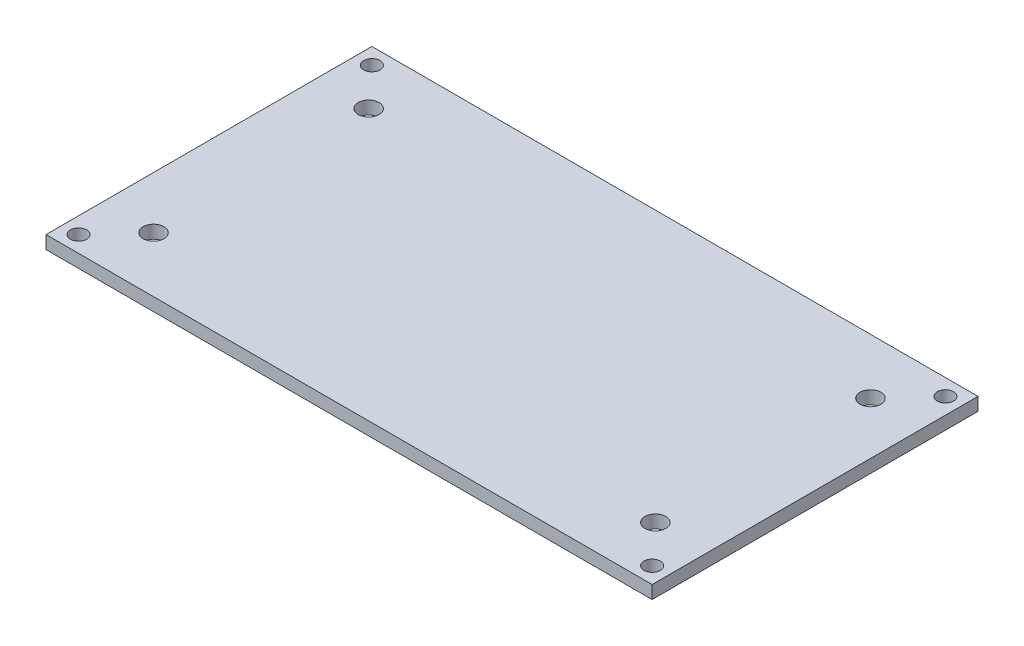
from build123d import *

# Parameters (mm, degrees)
SKETCH1_W           = 93
SKETCH1_H           = 50
BOSS_EXTRUDE1_DEPTH = 2
SKETCH2_R           = 1.25
CUT_EXTRUDE1_DEPTH  = 2
SKETCH3_R           = 1.6
CUT_EXTRUDE2_DEPTH  = 2


with BuildPart() as part:
    # Sketch1 → Boss-Extrude1 (new body)
    with BuildSketch(Plane(origin=(0, 0, 0), x_dir=(1, 0, 0), z_dir=(0, 1, 0))):
        Rectangle(SKETCH1_W, SKETCH1_H)
    extrude(amount=BOSS_EXTRUDE1_DEPTH)

    # Sketch2 → Cut-Extrude1 (cut)
    with BuildSketch(Plane(origin=(0, 2, 0), x_dir=(1, 0, 0), z_dir=(0, 1, 0))):
        with Locations((-44, 22.5)):
            Circle(SKETCH2_R)
        with Locations((44, 22.5)):
            Circle(SKETCH2_R)
        with Locations((44, -22.5)):
            Circle(SKETCH2_R)
        with Locations((-44, -22.5)):
            Circle(SKETCH2_R)
    extrude(amount=-CUT_EXTRUDE1_DEPTH, mode=Mode.SUBTRACT)

    # Sketch3 → Cut-Extrude2 (cut)
    with BuildSketch(Plane(origin=(0, 2, 0), x_dir=(1, 0, 0), z_dir=(0, 1, 0))):
        with Locations((-38.5, 16.5)):
            Circle(SKETCH3_R)
        with Locations((-38.5, -16.5)):
            Circle(SKETCH3_R)
        with Locations((38.5, 16.5)):
            Circle(SKETCH3_R)
        with Locations((38.5, -16.5)):
            Circle(SKETCH3_R)
    extrude(amount=-CUT_EXTRUDE2_DEPTH, mode=Mode.SUBTRACT)


solid = part.part
